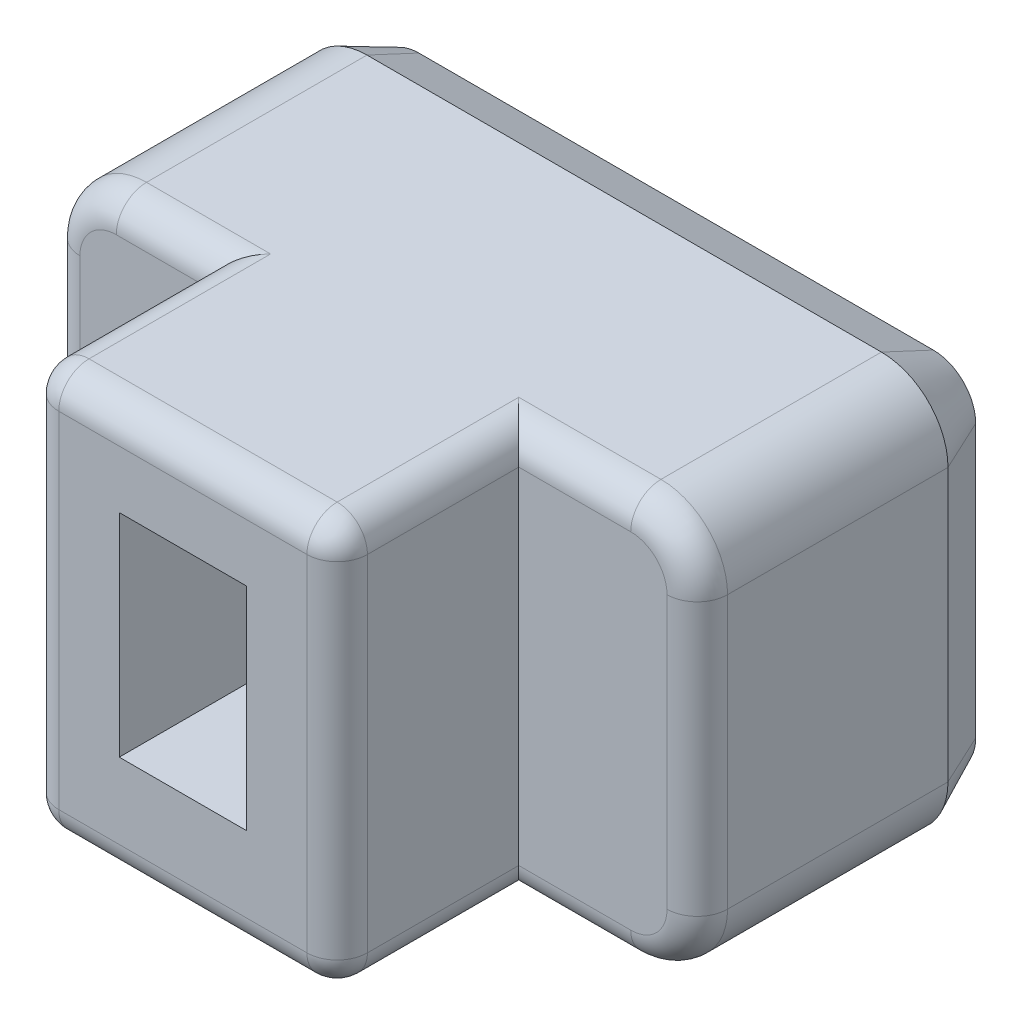
from build123d import *

# Parameters (mm, degrees)
BOSS_EXTRU_1_DEPTH      = 8
ESQUISSE3_W             = 2.1
ESQUISSE3_H             = 3.5
ENL_V_MAT_EXTRU_1_DEPTH = 3
ESQUISSE4_OUTSIDE_W     = 15.69
ESQUISSE4_OUTSIDE_H     = 11.69
ESQUISSE4_OUTSIDE_W_2   = 5.1
ESQUISSE4_OUTSIDE_H_2   = 6.7
ENL_V_MAT_EXTRU_2_DEPTH = 3
CONG_1_R                = 0.5
CHANFREIN1_SIZE         = 0.4
CHANFREIN1_SIZE2        = 0.857802768
ENL_V_MAT_EXTRU_3_DEPTH = 0.2
BOSS_EXTRU_2_DEPTH      = 0.2
BOSS_EXTRU_2_2_DEPTH    = 0.2
BOSS_EXTRU_2_3_DEPTH    = 0.2
BOSS_EXTRU_2_4_DEPTH    = 0.2


with BuildPart() as part:
    # Esquisse2 → Boss.-Extru.1 (new body)
    with BuildSketch(Plane.XY):
        with BuildLine():
            Line((1.1, 0), (9.6, 0))
            ThreePointArc((9.6, 0), (10.377817459, 0.322182541), (10.7, 1.1))
            Line((10.7, 1.1), (10.7, 5.6))
            ThreePointArc((10.7, 5.6), (10.377817459, 6.377817459), (9.6, 6.7))
            Line((9.6, 6.7), (1.1, 6.7))
            ThreePointArc((1.1, 6.7), (0.322182541, 6.377817459), (0, 5.6))
            Line((0, 5.6), (0, 1.1))
            ThreePointArc((0, 1.1), (0.322182541, 0.322182541), (1.1, 0))
        make_face()
    extrude(amount=BOSS_EXTRU_1_DEPTH)

    # Esquisse3 → Enlèv. mat.-Extru.1 (cut)
    with BuildSketch(Plane.XY.offset(8)):
        with Locations((5.2, 3.5)):
            Rectangle(ESQUISSE3_W, ESQUISSE3_H)
    extrude(amount=-ENL_V_MAT_EXTRU_1_DEPTH, mode=Mode.SUBTRACT)

    # Esquisse4 outside → Enlèv. mat.-Extru.2 (cut)
    with BuildSketch(Plane.XY.offset(8)):
        with Locations((5.35, 3.35)):
            Rectangle(ESQUISSE4_OUTSIDE_W, ESQUISSE4_OUTSIDE_H)
        with Locations((5.2, 3.35)):
            Rectangle(ESQUISSE4_OUTSIDE_W_2, ESQUISSE4_OUTSIDE_H_2, mode=Mode.SUBTRACT)
    extrude(amount=-ENL_V_MAT_EXTRU_2_DEPTH, mode=Mode.SUBTRACT)

    # Congé1
    cong_1_edges = [part.edges().sort_by_distance(p)[0] for p in [
        (8.675, 0, 5),
        (10.377817459, 0.322182541, 5),
        (10.7, 3.35, 5),
        (10.377817459, 6.377817459, 5),
        (1.875, 6.7, 5),
        (0.322182541, 6.377817459, 5),
        (1.875, 0, 5),
        (0.322182541, 0.322182541, 5),
        (7.75, 6.7, 6.5),
        (2.65, 6.7, 6.5),
        (7.75, 0, 6.5),
        (2.65, 0, 6.5),
        (2.65, 3.35, 8),
        (5.2, 6.7, 8),
        (7.75, 3.35, 8),
        (5.2, 0, 8),
        (8.675, 6.7, 5),
        (0, 3.35, 5),
    ]]
    fillet(cong_1_edges, radius=CONG_1_R)

    # Chanfrein1
    chanfrein1_edges = [part.edges().sort_by_distance(p)[0] for p in [
        (5.35, 0, 0),
        (10.377817459, 0.322182541, 0),
        (0.322182541, 0.322182541, 0),
        (10.7, 3.35, 0),
        (0, 3.35, 0),
        (10.377817459, 6.377817459, 0),
        (0.322182541, 6.377817459, 0),
        (5.35, 6.7, 0),
    ]]
    chanfrein1_side = [part.faces().sort_by_distance(p)[0] for p in [
        (5.35, 3.35, 0),
    ]]
    chamfer(chanfrein1_edges, length=CHANFREIN1_SIZE, length2=CHANFREIN1_SIZE2, reference=chanfrein1_side[0])

    # Esquisse5 → Enlèv. mat.-Extru.3 (cut)
    # profile 1 of 4: a face of its own
    with BuildSketch(Plane.XY):
        with BuildLine():
            Line((1.20670848, 5.092998901), (0.871123892, 5.092998901))
            Line((0.871123892, 5.092998901), (0.871123892, 1.592998901))
            Line((0.871123892, 1.592998901), (1.634520703, 1.592998901))
            add(Edge.make_bspline(
                [(1.634520703, 1.592998901), (1.689353961, 1.594367518), (1.795246849, 1.597010564), (1.947657519, 1.616349549), (2.088713626, 1.648486034), (2.175088244, 1.683567366), (2.217337355, 1.700726979)],
                knots=[0, 0, 0, 0, 1.102097031, 2.128347664, 3.084503667, 4, 4, 4, 4], degree=3))
            add(Edge.make_bspline(
                [(2.217337355, 1.700726979), (2.256896125, 1.720325727), (2.334514443, 1.75878046), (2.43587247, 1.838600916), (2.524236192, 1.929590111), (2.596121561, 2.03595902), (2.652111876, 2.155507809), (2.691215065, 2.288258291), (2.715784881, 2.433503983), (2.71826512, 2.534804351), (2.719551704, 2.587352311)],
                knots=[0, 0, 0, 0, 0.976045937, 1.915101135, 2.842441065, 3.7778061, 4.74596099, 5.756673503, 6.836309948, 8, 8, 8, 8], degree=3))
            add(Edge.make_bspline(
                [(2.719551704, 2.587352311), (2.718529752, 2.630547217), (2.716546192, 2.71438642), (2.700658457, 2.836048523), (2.675603103, 2.949993543), (2.63887122, 3.055945062), (2.592638071, 3.153883591), (2.536074802, 3.24313122), (2.470857764, 3.324340864), (2.395553699, 3.396786366), (2.31186018, 3.461450443), (2.218513643, 3.516384097), (2.117431288, 3.563907898), (2.007559255, 3.602622144), (1.889407218, 3.632260485), (1.763942002, 3.655261776), (1.630613092, 3.667057182), (1.539470735, 3.669040369), (1.492691651, 3.670058246)],
                knots=[0, 0, 0, 0, 1.113353749, 2.160965244, 3.15799471, 4.11645282, 5.04602989, 5.944145942, 6.834621692, 7.724923037, 8.632205657, 9.555220642, 10.511732549, 11.508227868, 12.553486201, 13.6497118, 14.793707635, 16, 16, 16, 16], degree=3))
            add(Edge.make_bspline(
                [(1.492691651, 3.670058246), (1.445900058, 3.669361357), (1.350371393, 3.667938604), (1.255241901, 3.659078218), (1.20670848, 3.654557803)],
                knots=[0, 0, 0, 0, 0.979634597, 2, 2, 2, 2], degree=3))
            Line((1.20670848, 3.654557803), (1.20670848, 5.092998901))
        make_face()
        with BuildLine():
            add(Edge.make_bspline(
                [(1.20670848, 3.264721664), (1.229671176, 3.268081612), (1.276756003, 3.274971157), (1.3479601, 3.280390103), (1.418758831, 3.284559247), (1.465301481, 3.285290153), (1.488041518, 3.285647262)],
                knots=[0, 0, 0, 0, 0.986049358, 2.021886482, 3.033523553, 4, 4, 4, 4], degree=3))
            add(Edge.make_bspline(
                [(1.488041518, 3.285647262), (1.526033878, 3.285026949), (1.599277371, 3.283831079), (1.704923877, 3.275442513), (1.801915788, 3.26117826), (1.890208061, 3.239996412), (1.970300734, 3.214083964), (2.042403598, 3.181938969), (2.107176038, 3.144981274), (2.16398, 3.102059255), (2.213753248, 3.054596832), (2.254713635, 3.000969926), (2.290242232, 2.943718918), (2.317088589, 2.880777273), (2.338130446, 2.813793991), (2.352715406, 2.742110051), (2.361142672, 2.666090665), (2.362399302, 2.613982705), (2.363041518, 2.587352311)],
                knots=[0, 0, 0, 0, 1.420648392, 2.738794025, 3.960251778, 5.082640406, 6.130503421, 7.103552109, 8.029821208, 8.912811201, 9.75998344, 10.592879125, 11.429575965, 12.273160229, 13.143963859, 14.051504125, 15.004197952, 16, 16, 16, 16], degree=3))
            add(Edge.make_bspline(
                [(2.363041518, 2.587352311), (2.362321145, 2.554733507), (2.360940765, 2.49222923), (2.34573986, 2.402990773), (2.322381391, 2.322667118), (2.288587259, 2.251487343), (2.245313146, 2.18944241), (2.193567559, 2.135680811), (2.134230371, 2.089034617), (2.089609635, 2.065364734), (2.066983059, 2.053362054)],
                knots=[0, 0, 0, 0, 1.207165636, 2.313175352, 3.342544525, 4.297084662, 5.218277657, 6.132034109, 7.052779621, 8, 8, 8, 8], degree=3))
            add(Edge.make_bspline(
                [(2.066983059, 2.053362054), (2.035529134, 2.040463055), (1.969781048, 2.013500298), (1.858571937, 1.991798742), (1.732712702, 1.980100484), (1.643338394, 1.978344496), (1.595769596, 1.977409884)],
                knots=[0, 0, 0, 0, 0.846695568, 1.769846298, 2.813017582, 4, 4, 4, 4], degree=3))
            Line((1.595769596, 1.977409884), (1.20670848, 1.977409884))
            Line((1.20670848, 1.977409884), (1.20670848, 3.264721664))
        make_face(mode=Mode.SUBTRACT)
    # profile 2 of 4: a face of its own
    with BuildSketch(Plane.XY):
        with BuildLine():
            Line((3.339569419, 3.643707493), (3.339569419, 5.092998901))
            Line((3.339569419, 5.092998901), (3.003984831, 5.092998901))
            Line((3.003984831, 5.092998901), (3.003984831, 1.592998901))
            Line((3.003984831, 1.592998901), (3.717780225, 1.592998901))
            add(Edge.make_bspline(
                [(3.717780225, 1.592998901), (3.746982879, 1.592935819), (3.802834183, 1.592815172), (3.883381251, 1.597737699), (3.957195982, 1.601183031), (4.044703681, 1.612039358), (4.145135568, 1.628362438), (4.220721824, 1.65208075), (4.257195637, 1.663525916)],
                knots=[0, 0, 0, 0, 0.96148623, 1.838882832, 2.657282477, 3.393934539, 4.742454682, 6, 6, 6, 6], degree=3))
            add(Edge.make_bspline(
                [(4.257195637, 1.663525916), (4.280609086, 1.672178019), (4.326903922, 1.689285608), (4.392540271, 1.721345141), (4.454432924, 1.757013696), (4.511692206, 1.797599405), (4.565569714, 1.841620067), (4.614649251, 1.890686567), (4.658637934, 1.944584606), (4.699469971, 2.001956268), (4.734605541, 2.064027652), (4.766194985, 2.129270366), (4.791394771, 2.199092325), (4.813285194, 2.271936008), (4.829227361, 2.349035135), (4.841984322, 2.42940088), (4.84872659, 2.513867404), (4.849628953, 2.571324986), (4.850087577, 2.600527688)],
                knots=[0, 0, 0, 0, 1.004278728, 1.985735529, 2.936460815, 3.877064109, 4.807842092, 5.73442736, 6.665205342, 7.605808636, 8.565535541, 9.533119072, 10.520289732, 11.550301557, 12.59263054, 13.686946876, 14.824395376, 16, 16, 16, 16], degree=3))
            add(Edge.make_bspline(
                [(4.850087577, 2.600527688), (4.849569701, 2.634910342), (4.848558825, 2.702024148), (4.838465372, 2.799764421), (4.821149651, 2.89190843), (4.798389226, 2.978664886), (4.768334399, 3.059784167), (4.734190517, 3.135669567), (4.693043686, 3.205346594), (4.647555952, 3.270012568), (4.596055895, 3.328579978), (4.541102893, 3.382907186), (4.48011641, 3.430141905), (4.414672962, 3.471733862), (4.345755669, 3.50971036), (4.271954689, 3.539640604), (4.195474158, 3.567142), (4.142380634, 3.579876517), (4.115366585, 3.586355854)],
                knots=[0, 0, 0, 0, 1.228411642, 2.397818991, 3.505967096, 4.576401872, 5.598614386, 6.594173708, 7.545786843, 8.485911268, 9.41518476, 10.329199726, 11.243354554, 12.165261513, 13.098790089, 14.050403223, 15.008042817, 16, 16, 16, 16], degree=3))
            Line((4.115366585, 3.586355854), (4.115366585, 3.596431142))
            Line((4.115366585, 3.596431142), (5.015167293, 5.092998901))
            Line((5.015167293, 5.092998901), (4.592780225, 5.092998901))
            Line((4.592780225, 5.092998901), (3.744906, 3.643707493))
            Line((3.744906, 3.643707493), (3.339569419, 3.643707493))
        make_face()
        with BuildLine():
            Line((3.339569419, 1.977409884), (3.339569419, 3.259296509))
            Line((3.339569419, 3.259296509), (3.670503874, 3.259296509))
            add(Edge.make_bspline(
                [(3.670503874, 3.259296509), (3.695304806, 3.259133428), (3.742851898, 3.258820777), (3.811635042, 3.256848889), (3.874638922, 3.251764529), (3.949951818, 3.245312963), (4.035695985, 3.23085379), (4.099566685, 3.209195698), (4.130092005, 3.198844782)],
                knots=[0, 0, 0, 0, 0.957884705, 1.836408112, 2.656744154, 3.398369538, 4.756619154, 6, 6, 6, 6], degree=3))
            add(Edge.make_bspline(
                [(4.130092005, 3.198844782), (4.157934618, 3.186806116), (4.212462715, 3.163229106), (4.285696193, 3.113144417), (4.349026944, 3.05297611), (4.402411758, 2.982563114), (4.444290573, 2.900835637), (4.473029143, 2.807752339), (4.491103228, 2.703524253), (4.493236107, 2.630317432), (4.494352413, 2.592002444)],
                knots=[0, 0, 0, 0, 0.958661377, 1.877481189, 2.791628759, 3.714299863, 4.66179935, 5.683601886, 6.787643488, 8, 8, 8, 8], degree=3))
            add(Edge.make_bspline(
                [(4.494352413, 2.592002444), (4.493252095, 2.556261938), (4.491147907, 2.48791375), (4.472923198, 2.391293858), (4.445287627, 2.305165185), (4.406502678, 2.229721317), (4.356606176, 2.165698549), (4.299351757, 2.110302397), (4.233092329, 2.064732747), (4.183717992, 2.043278074), (4.158767825, 2.032436456)],
                knots=[0, 0, 0, 0, 1.228800359, 2.349890542, 3.370317647, 4.332513309, 5.251741842, 6.15080521, 7.065552617, 8, 8, 8, 8], degree=3))
            add(Edge.make_bspline(
                [(4.158767825, 2.032436456), (4.131820833, 2.023499284), (4.073957624, 2.004308515), (3.995358463, 1.991386976), (3.92399037, 1.984871624), (3.8622725, 1.979816467), (3.793486428, 1.977877641), (3.745422803, 1.977571267), (3.720105291, 1.977409884)],
                knots=[0, 0, 0, 0, 1.148741759, 2.466690436, 3.213321058, 4.052887216, 4.974358485, 6, 6, 6, 6], degree=3))
            Line((3.720105291, 1.977409884), (3.339569419, 1.977409884))
        make_face(mode=Mode.SUBTRACT)
    # profile 3 of 4: a face of its own
    with BuildSketch(Plane.XY):
        with BuildLine():
            add(Edge.make_bspline(
                [(7.71844453, 3.345323967), (7.717490823, 3.410204476), (7.715617955, 3.537615321), (7.698300865, 3.724589286), (7.669558866, 3.90344507), (7.630568495, 4.073779802), (7.580167736, 4.234037989), (7.520625348, 4.383832581), (7.451011567, 4.521908825), (7.371748918, 4.648620785), (7.282545439, 4.762283337), (7.185578837, 4.864405018), (7.078408921, 4.95147494), (6.963535828, 5.025627742), (6.840555598, 5.084922143), (6.709957694, 5.128180687), (6.571846524, 5.153103959), (6.477474066, 5.156418649), (6.429582705, 5.158100761)],
                knots=[0, 0, 0, 0, 1.254401412, 2.463364559, 3.627141903, 4.75533473, 5.83922306, 6.872651372, 7.869084623, 8.825439613, 9.757825438, 10.658779487, 11.542787756, 12.421358886, 13.297241529, 14.175599587, 15.074168247, 16, 16, 16, 16], degree=3))
            add(Edge.make_bspline(
                [(6.429582705, 5.158100761), (6.380139139, 5.156448782), (6.283192758, 5.153209667), (6.141537726, 5.128126273), (6.008179731, 5.085294289), (5.883344048, 5.025541428), (5.766945237, 4.952015382), (5.659775215, 4.864019715), (5.561704334, 4.763090778), (5.474522259, 4.648005694), (5.394739066, 4.522193813), (5.326280438, 4.383725792), (5.267139118, 4.23416755), (5.218785937, 4.073586542), (5.180247458, 3.90344204), (5.152322236, 3.724555778), (5.136004659, 3.537578413), (5.133994475, 3.410199769), (5.132970659, 3.345323967)],
                knots=[0, 0, 0, 0, 0.95135505, 1.865367647, 2.758596585, 3.639420318, 4.522333025, 5.402272009, 6.302532509, 7.224531664, 8.17648434, 9.166096968, 10.192927605, 11.268888898, 12.390775886, 13.548416718, 14.751372875, 16, 16, 16, 16], degree=3))
            add(Edge.make_bspline(
                [(5.132970659, 3.345323967), (5.133909926, 3.279924761), (5.135750982, 3.151735858), (5.153201585, 2.963758231), (5.181562496, 2.783975058), (5.221957953, 2.613154279), (5.271590455, 2.451965447), (5.332525486, 2.302332204), (5.40211655, 2.163948858), (5.480816103, 2.037035708), (5.569885489, 1.923447935), (5.666578795, 1.821540487), (5.774026866, 1.734641948), (5.88857793, 1.659320523), (6.012320582, 1.600141415), (6.143708493, 1.55815348), (6.282379938, 1.532716971), (6.377289501, 1.529525281), (6.425707594, 1.527897041)],
                knots=[0, 0, 0, 0, 1.2604387, 2.470584333, 3.635642921, 4.76629325, 5.851547647, 6.883611372, 7.876931566, 8.834516682, 9.756999016, 10.655138303, 11.536384754, 12.414911192, 13.292547926, 14.171356622, 15.067117974, 16, 16, 16, 16], degree=3))
            add(Edge.make_bspline(
                [(6.425707594, 1.527897041), (6.474898321, 1.529530042), (6.571342357, 1.532731728), (6.712082462, 1.55806652), (6.845078706, 1.599968235), (6.969763269, 1.659351787), (7.085036042, 1.734402747), (7.192578769, 1.821561914), (7.289242198, 1.923467324), (7.378431123, 2.036823797), (7.456190042, 2.164031677), (7.525243653, 2.302191567), (7.584408512, 2.45206405), (7.63252958, 2.613207532), (7.671496284, 2.784025202), (7.69777052, 2.963900011), (7.715784212, 3.151719212), (7.717545804, 3.279919138), (7.71844453, 3.345323967)],
                knots=[0, 0, 0, 0, 0.945875137, 1.854496205, 2.740991389, 3.62133533, 4.502254271, 5.381713945, 6.278032205, 7.198644155, 8.151660626, 9.140734204, 10.167005517, 11.247136334, 12.373259138, 13.534424914, 14.742116909, 16, 16, 16, 16], degree=3))
        make_face()
        with BuildLine():
            add(Edge.make_bspline(
                [(7.36425941, 3.345323967), (7.363354318, 3.28820498), (7.361598928, 3.177425057), (7.348433043, 3.01638856), (7.326324974, 2.865602316), (7.294636917, 2.725517513), (7.255145807, 2.596265005), (7.208639661, 2.478131695), (7.156071809, 2.370489112), (7.096713344, 2.273632496), (7.029160994, 2.189249979), (6.958267959, 2.113595029), (6.879912968, 2.050662233), (6.796874023, 1.998149659), (6.708762004, 1.958131515), (6.617491987, 1.927858599), (6.522438515, 1.910864821), (6.458062135, 1.908214752), (6.425707594, 1.906882869)],
                knots=[0, 0, 0, 0, 1.431659839, 2.776645253, 4.046892239, 5.248691002, 6.373248433, 7.431467862, 8.427717902, 9.372927974, 10.27202652, 11.133077176, 11.96643372, 12.783965196, 13.589482426, 14.386100375, 15.188879826, 16, 16, 16, 16], degree=3))
            add(Edge.make_bspline(
                [(6.425707594, 1.906882869), (6.393352979, 1.908214682), (6.32897645, 1.910864612), (6.233924081, 1.927859421), (6.142649901, 1.958128445), (6.054553658, 1.99816134), (5.971454451, 2.050617568), (5.89319208, 2.113880581), (5.821396868, 2.188722678), (5.754775476, 2.273920937), (5.695491357, 2.370663517), (5.641630598, 2.477745284), (5.596568914, 2.596488274), (5.556681609, 2.72547817), (5.525118461, 2.865613813), (5.502973947, 3.016385224), (5.489818517, 3.177425975), (5.488061639, 3.288205292), (5.487155779, 3.345323967)],
                knots=[0, 0, 0, 0, 0.81106871, 1.613797227, 2.410364633, 3.215830754, 4.03331036, 4.86661403, 5.732102977, 6.627148042, 7.572298143, 8.57136398, 9.627155934, 10.751642014, 11.953364526, 13.223530918, 14.568430996, 16, 16, 16, 16], degree=3))
            add(Edge.make_bspline(
                [(5.487155779, 3.345323967), (5.48810114, 3.402437635), (5.489938892, 3.513464713), (5.50258263, 3.674613838), (5.526108626, 3.824975597), (5.557581256, 3.964606764), (5.597132843, 4.093571347), (5.643223298, 4.211758064), (5.697042295, 4.318872581), (5.757247215, 4.41490553), (5.823397966, 4.500425204), (5.89584375, 4.574357032), (5.973495221, 4.637894177), (6.057164378, 4.689142394), (6.144985026, 4.729894191), (6.236981307, 4.758468335), (6.332273497, 4.77625025), (6.396954406, 4.778154389), (6.429582705, 4.779114933)],
                knots=[0, 0, 0, 0, 1.43184294, 2.783455283, 4.048438288, 5.244075095, 6.36877635, 7.42713112, 8.420599559, 9.369363064, 10.264579399, 11.125594041, 11.959057166, 12.773274533, 13.578894784, 14.379815369, 15.182697491, 16, 16, 16, 16], degree=3))
            add(Edge.make_bspline(
                [(6.429582705, 4.779114933), (6.461950884, 4.778146752), (6.526115323, 4.776227496), (6.6204308, 4.758602085), (6.711299616, 4.729711271), (6.798144113, 4.689143205), (6.881065287, 4.637894479), (6.957951652, 4.574110175), (7.030333788, 4.500432503), (7.096541848, 4.415099793), (7.155931452, 4.318826963), (7.208825397, 4.211567097), (7.255125763, 4.093598017), (7.294529869, 3.964589912), (7.326337072, 3.825055477), (7.34853709, 3.67452883), (7.361558319, 3.513477368), (7.36334191, 3.402441933), (7.36425941, 3.345323967)],
                knots=[0, 0, 0, 0, 0.813321926, 1.612273121, 2.403261148, 3.205454394, 4.016646045, 4.847626393, 5.711280782, 6.609241721, 7.557470929, 8.551079935, 9.612679468, 10.740828895, 11.940131352, 13.208011044, 14.563767236, 16, 16, 16, 16], degree=3))
        make_face(mode=Mode.SUBTRACT)
    # profile 4 of 4: a face of its own
    with BuildSketch(Plane.XY):
        with BuildLine():
            add(Edge.make_bspline(
                [(9.401017603, 1.906882869), (9.363499186, 1.90818258), (9.289367236, 1.910750655), (9.179784589, 1.927987062), (9.074406065, 1.957680591), (8.972941262, 1.998155453), (8.876272181, 2.049711686), (8.787273041, 2.115127472), (8.703129014, 2.189927999), (8.6266481, 2.277014469), (8.557354227, 2.375648594), (8.495491166, 2.484876528), (8.441894475, 2.605401829), (8.396307884, 2.736821056), (8.358904164, 2.879448886), (8.332974512, 3.033754076), (8.317527869, 3.199044062), (8.315487307, 3.312996837), (8.314436558, 3.37167472)],
                knots=[0, 0, 0, 0, 0.879992269, 1.7387605, 2.594444558, 3.442888612, 4.296961918, 5.156371292, 6.027472405, 6.933290606, 7.86807611, 8.85043868, 9.873020297, 10.957722873, 12.11002158, 13.327402364, 14.62379506, 16, 16, 16, 16], degree=3))
            add(Edge.make_bspline(
                [(8.314436558, 3.37167472), (8.315218843, 3.429832766), (8.316733983, 3.542474004), (8.331469627, 3.705407432), (8.35616246, 3.856406629), (8.389869406, 3.995749624), (8.433439182, 4.123176742), (8.484558712, 4.239617688), (8.543800679, 4.344865165), (8.612841547, 4.437547604), (8.688288843, 4.519864001), (8.771631718, 4.590997053), (8.862922426, 4.650179716), (8.961471347, 4.69771972), (9.066482804, 4.733763946), (9.176983442, 4.76031743), (9.293359199, 4.775961769), (9.372811, 4.778048452), (9.413417957, 4.779114933)],
                knots=[0, 0, 0, 0, 1.376668534, 2.666348994, 3.868955176, 4.996373325, 6.056321508, 7.053061798, 8.00363822, 8.908879053, 9.783196614, 10.642321006, 11.495656305, 12.35188012, 13.226197681, 14.119268927, 15.038778669, 16, 16, 16, 16], degree=3))
            add(Edge.make_bspline(
                [(9.413417957, 4.779114933), (9.436685656, 4.778644332), (9.484867225, 4.777669834), (9.558292286, 4.770182928), (9.634422492, 4.759659113), (9.710868671, 4.744021918), (9.786810014, 4.725384649), (9.85992275, 4.704658998), (9.92889931, 4.683436183), (9.971319827, 4.66479261), (9.991584476, 4.655886412)],
                knots=[0, 0, 0, 0, 0.938891291, 1.944208406, 2.976362877, 4.039644555, 5.091619871, 6.131382141, 7.107344988, 8, 8, 8, 8], degree=3))
            Line((9.991584476, 4.655886412), (9.991584476, 5.032547174))
            add(Edge.make_bspline(
                [(9.991584476, 5.032547174), (9.970816832, 5.042481872), (9.928211789, 5.062863012), (9.859667897, 5.086888391), (9.786867029, 5.10895653), (9.682671068, 5.132238066), (9.547076979, 5.15419478), (9.436512363, 5.15679308), (9.380867027, 5.158100761)],
                knots=[0, 0, 0, 0, 0.65879011, 1.351514929, 2.077116164, 2.836224988, 4.407724579, 6, 6, 6, 6], degree=3))
            add(Edge.make_bspline(
                [(9.380867027, 5.158100761), (9.324987198, 5.156628633), (9.216114259, 5.153760427), (9.057839708, 5.131006778), (8.909454511, 5.093388589), (8.771411734, 5.039183231), (8.643186281, 4.972071609), (8.525560507, 4.890532912), (8.419249455, 4.795470688), (8.322996198, 4.687766873), (8.238724426, 4.566536774), (8.163623012, 4.433879772), (8.102084701, 4.287299743), (8.050372026, 4.129182281), (8.009202649, 3.959507315), (7.981301328, 3.778263776), (7.962740199, 3.586485504), (7.961093965, 3.454648191), (7.960251438, 3.387175163)],
                knots=[0, 0, 0, 0, 1.042402955, 2.030955957, 2.976872811, 3.892693394, 4.79191998, 5.671840379, 6.556199892, 7.447365694, 8.360848699, 9.30622489, 10.286740406, 11.321861055, 12.408087922, 13.540642029, 14.741325001, 16, 16, 16, 16], degree=3))
            add(Edge.make_bspline(
                [(7.960251438, 3.387175163), (7.961486458, 3.320487695), (7.963908384, 3.189710631), (7.981631912, 2.997442746), (8.012838575, 2.813658607), (8.055019781, 2.638393656), (8.109156307, 2.473276979), (8.173988439, 2.31926326), (8.250293058, 2.177310496), (8.336987814, 2.047574907), (8.434011591, 1.930522095), (8.541833875, 1.82748378), (8.659285388, 1.737978092), (8.785957559, 1.662353558), (8.921730606, 1.602267564), (9.065808285, 1.558675263), (9.218455729, 1.532556005), (9.322895701, 1.529471709), (9.376216895, 1.527897041)],
                knots=[0, 0, 0, 0, 1.222049748, 2.396493403, 3.534403425, 4.635595668, 5.697072746, 6.715343596, 7.693969664, 8.645951101, 9.57036278, 10.474462782, 11.373067138, 12.271072658, 13.171906666, 14.087009169, 15.023334156, 16, 16, 16, 16], degree=3))
            add(Edge.make_bspline(
                [(9.376216895, 1.527897041), (9.40489793, 1.528442114), (9.46206628, 1.529528577), (9.547049742, 1.535224163), (9.629390208, 1.547496167), (9.708229495, 1.561479632), (9.782091473, 1.580508862), (9.850432382, 1.601443109), (9.911221925, 1.625913241), (9.948039326, 1.644684233), (9.965233724, 1.653450628)],
                knots=[0, 0, 0, 0, 1.132578206, 2.257506571, 3.35954441, 4.417807573, 5.417220349, 6.368856758, 7.238226401, 8, 8, 8, 8], degree=3))
            Line((9.965233724, 1.653450628), (9.965233724, 2.03011139))
            add(Edge.make_bspline(
                [(9.965233724, 2.03011139), (9.922312104, 2.013453379), (9.834015078, 1.979185037), (9.694921987, 1.939289388), (9.549336302, 1.911645899), (9.450224476, 1.908463073), (9.401017603, 1.906882869)],
                knots=[0, 0, 0, 0, 0.950326369, 1.954981939, 2.984692879, 4, 4, 4, 4], degree=3))
        make_face()
    extrude(amount=ENL_V_MAT_EXTRU_3_DEPTH, mode=Mode.SUBTRACT)


with BuildPart() as body_2:
    # Esquisse5_4 → Boss.-Extru.2 (new body)
    with BuildSketch(Plane.XY):
        with BuildLine():
            Line((1.20670848, 5.092998901), (0.871123892, 5.092998901))
            Line((0.871123892, 5.092998901), (0.871123892, 1.592998901))
            Line((0.871123892, 1.592998901), (1.634520703, 1.592998901))
            add(Edge.make_bspline(
                [(1.634520703, 1.592998901), (1.689353961, 1.594367518), (1.795246849, 1.597010564), (1.947657519, 1.616349549), (2.088713626, 1.648486034), (2.175088244, 1.683567366), (2.217337355, 1.700726979)],
                knots=[0, 0, 0, 0, 1.102097031, 2.128347664, 3.084503667, 4, 4, 4, 4], degree=3))
            add(Edge.make_bspline(
                [(2.217337355, 1.700726979), (2.256896125, 1.720325727), (2.334514443, 1.75878046), (2.43587247, 1.838600916), (2.524236192, 1.929590111), (2.596121561, 2.03595902), (2.652111876, 2.155507809), (2.691215065, 2.288258291), (2.715784881, 2.433503983), (2.71826512, 2.534804351), (2.719551704, 2.587352311)],
                knots=[0, 0, 0, 0, 0.976045937, 1.915101135, 2.842441065, 3.7778061, 4.74596099, 5.756673503, 6.836309948, 8, 8, 8, 8], degree=3))
            add(Edge.make_bspline(
                [(2.719551704, 2.587352311), (2.718529752, 2.630547217), (2.716546192, 2.71438642), (2.700658457, 2.836048523), (2.675603103, 2.949993543), (2.63887122, 3.055945062), (2.592638071, 3.153883591), (2.536074802, 3.24313122), (2.470857764, 3.324340864), (2.395553699, 3.396786366), (2.31186018, 3.461450443), (2.218513643, 3.516384097), (2.117431288, 3.563907898), (2.007559255, 3.602622144), (1.889407218, 3.632260485), (1.763942002, 3.655261776), (1.630613092, 3.667057182), (1.539470735, 3.669040369), (1.492691651, 3.670058246)],
                knots=[0, 0, 0, 0, 1.113353749, 2.160965244, 3.15799471, 4.11645282, 5.04602989, 5.944145942, 6.834621692, 7.724923037, 8.632205657, 9.555220642, 10.511732549, 11.508227868, 12.553486201, 13.6497118, 14.793707635, 16, 16, 16, 16], degree=3))
            add(Edge.make_bspline(
                [(1.492691651, 3.670058246), (1.445900058, 3.669361357), (1.350371393, 3.667938604), (1.255241901, 3.659078218), (1.20670848, 3.654557803)],
                knots=[0, 0, 0, 0, 0.979634597, 2, 2, 2, 2], degree=3))
            Line((1.20670848, 3.654557803), (1.20670848, 5.092998901))
        make_face()
        with BuildLine():
            add(Edge.make_bspline(
                [(1.20670848, 3.264721664), (1.229671176, 3.268081612), (1.276756003, 3.274971157), (1.3479601, 3.280390103), (1.418758831, 3.284559247), (1.465301481, 3.285290153), (1.488041518, 3.285647262)],
                knots=[0, 0, 0, 0, 0.986049358, 2.021886482, 3.033523553, 4, 4, 4, 4], degree=3))
            add(Edge.make_bspline(
                [(1.488041518, 3.285647262), (1.526033878, 3.285026949), (1.599277371, 3.283831079), (1.704923877, 3.275442513), (1.801915788, 3.26117826), (1.890208061, 3.239996412), (1.970300734, 3.214083964), (2.042403598, 3.181938969), (2.107176038, 3.144981274), (2.16398, 3.102059255), (2.213753248, 3.054596832), (2.254713635, 3.000969926), (2.290242232, 2.943718918), (2.317088589, 2.880777273), (2.338130446, 2.813793991), (2.352715406, 2.742110051), (2.361142672, 2.666090665), (2.362399302, 2.613982705), (2.363041518, 2.587352311)],
                knots=[0, 0, 0, 0, 1.420648392, 2.738794025, 3.960251778, 5.082640406, 6.130503421, 7.103552109, 8.029821208, 8.912811201, 9.75998344, 10.592879125, 11.429575965, 12.273160229, 13.143963859, 14.051504125, 15.004197952, 16, 16, 16, 16], degree=3))
            add(Edge.make_bspline(
                [(2.363041518, 2.587352311), (2.362321145, 2.554733507), (2.360940765, 2.49222923), (2.34573986, 2.402990773), (2.322381391, 2.322667118), (2.288587259, 2.251487343), (2.245313146, 2.18944241), (2.193567559, 2.135680811), (2.134230371, 2.089034617), (2.089609635, 2.065364734), (2.066983059, 2.053362054)],
                knots=[0, 0, 0, 0, 1.207165636, 2.313175352, 3.342544525, 4.297084662, 5.218277657, 6.132034109, 7.052779621, 8, 8, 8, 8], degree=3))
            add(Edge.make_bspline(
                [(2.066983059, 2.053362054), (2.035529134, 2.040463055), (1.969781048, 2.013500298), (1.858571937, 1.991798742), (1.732712702, 1.980100484), (1.643338394, 1.978344496), (1.595769596, 1.977409884)],
                knots=[0, 0, 0, 0, 0.846695568, 1.769846298, 2.813017582, 4, 4, 4, 4], degree=3))
            Line((1.595769596, 1.977409884), (1.20670848, 1.977409884))
            Line((1.20670848, 1.977409884), (1.20670848, 3.264721664))
        make_face(mode=Mode.SUBTRACT)
    extrude(amount=-BOSS_EXTRU_2_DEPTH)


with BuildPart() as body_3:
    # Esquisse5_4 → Boss.-Extru.2 2 (new body)
    with BuildSketch(Plane.XY):
        with BuildLine():
            Line((3.339569419, 3.643707493), (3.339569419, 5.092998901))
            Line((3.339569419, 5.092998901), (3.003984831, 5.092998901))
            Line((3.003984831, 5.092998901), (3.003984831, 1.592998901))
            Line((3.003984831, 1.592998901), (3.717780225, 1.592998901))
            add(Edge.make_bspline(
                [(3.717780225, 1.592998901), (3.746982879, 1.592935819), (3.802834183, 1.592815172), (3.883381251, 1.597737699), (3.957195982, 1.601183031), (4.044703681, 1.612039358), (4.145135568, 1.628362438), (4.220721824, 1.65208075), (4.257195637, 1.663525916)],
                knots=[0, 0, 0, 0, 0.96148623, 1.838882832, 2.657282477, 3.393934539, 4.742454682, 6, 6, 6, 6], degree=3))
            add(Edge.make_bspline(
                [(4.257195637, 1.663525916), (4.280609086, 1.672178019), (4.326903922, 1.689285608), (4.392540271, 1.721345141), (4.454432924, 1.757013696), (4.511692206, 1.797599405), (4.565569714, 1.841620067), (4.614649251, 1.890686567), (4.658637934, 1.944584606), (4.699469971, 2.001956268), (4.734605541, 2.064027652), (4.766194985, 2.129270366), (4.791394771, 2.199092325), (4.813285194, 2.271936008), (4.829227361, 2.349035135), (4.841984322, 2.42940088), (4.84872659, 2.513867404), (4.849628953, 2.571324986), (4.850087577, 2.600527688)],
                knots=[0, 0, 0, 0, 1.004278728, 1.985735529, 2.936460815, 3.877064109, 4.807842092, 5.73442736, 6.665205342, 7.605808636, 8.565535541, 9.533119072, 10.520289732, 11.550301557, 12.59263054, 13.686946876, 14.824395376, 16, 16, 16, 16], degree=3))
            add(Edge.make_bspline(
                [(4.850087577, 2.600527688), (4.849569701, 2.634910342), (4.848558825, 2.702024148), (4.838465372, 2.799764421), (4.821149651, 2.89190843), (4.798389226, 2.978664886), (4.768334399, 3.059784167), (4.734190517, 3.135669567), (4.693043686, 3.205346594), (4.647555952, 3.270012568), (4.596055895, 3.328579978), (4.541102893, 3.382907186), (4.48011641, 3.430141905), (4.414672962, 3.471733862), (4.345755669, 3.50971036), (4.271954689, 3.539640604), (4.195474158, 3.567142), (4.142380634, 3.579876517), (4.115366585, 3.586355854)],
                knots=[0, 0, 0, 0, 1.228411642, 2.397818991, 3.505967096, 4.576401872, 5.598614386, 6.594173708, 7.545786843, 8.485911268, 9.41518476, 10.329199726, 11.243354554, 12.165261513, 13.098790089, 14.050403223, 15.008042817, 16, 16, 16, 16], degree=3))
            Line((4.115366585, 3.586355854), (4.115366585, 3.596431142))
            Line((4.115366585, 3.596431142), (5.015167293, 5.092998901))
            Line((5.015167293, 5.092998901), (4.592780225, 5.092998901))
            Line((4.592780225, 5.092998901), (3.744906, 3.643707493))
            Line((3.744906, 3.643707493), (3.339569419, 3.643707493))
        make_face()
        with BuildLine():
            Line((3.339569419, 1.977409884), (3.339569419, 3.259296509))
            Line((3.339569419, 3.259296509), (3.670503874, 3.259296509))
            add(Edge.make_bspline(
                [(3.670503874, 3.259296509), (3.695304806, 3.259133428), (3.742851898, 3.258820777), (3.811635042, 3.256848889), (3.874638922, 3.251764529), (3.949951818, 3.245312963), (4.035695985, 3.23085379), (4.099566685, 3.209195698), (4.130092005, 3.198844782)],
                knots=[0, 0, 0, 0, 0.957884705, 1.836408112, 2.656744154, 3.398369538, 4.756619154, 6, 6, 6, 6], degree=3))
            add(Edge.make_bspline(
                [(4.130092005, 3.198844782), (4.157934618, 3.186806116), (4.212462715, 3.163229106), (4.285696193, 3.113144417), (4.349026944, 3.05297611), (4.402411758, 2.982563114), (4.444290573, 2.900835637), (4.473029143, 2.807752339), (4.491103228, 2.703524253), (4.493236107, 2.630317432), (4.494352413, 2.592002444)],
                knots=[0, 0, 0, 0, 0.958661377, 1.877481189, 2.791628759, 3.714299863, 4.66179935, 5.683601886, 6.787643488, 8, 8, 8, 8], degree=3))
            add(Edge.make_bspline(
                [(4.494352413, 2.592002444), (4.493252095, 2.556261938), (4.491147907, 2.48791375), (4.472923198, 2.391293858), (4.445287627, 2.305165185), (4.406502678, 2.229721317), (4.356606176, 2.165698549), (4.299351757, 2.110302397), (4.233092329, 2.064732747), (4.183717992, 2.043278074), (4.158767825, 2.032436456)],
                knots=[0, 0, 0, 0, 1.228800359, 2.349890542, 3.370317647, 4.332513309, 5.251741842, 6.15080521, 7.065552617, 8, 8, 8, 8], degree=3))
            add(Edge.make_bspline(
                [(4.158767825, 2.032436456), (4.131820833, 2.023499284), (4.073957624, 2.004308515), (3.995358463, 1.991386976), (3.92399037, 1.984871624), (3.8622725, 1.979816467), (3.793486428, 1.977877641), (3.745422803, 1.977571267), (3.720105291, 1.977409884)],
                knots=[0, 0, 0, 0, 1.148741759, 2.466690436, 3.213321058, 4.052887216, 4.974358485, 6, 6, 6, 6], degree=3))
            Line((3.720105291, 1.977409884), (3.339569419, 1.977409884))
        make_face(mode=Mode.SUBTRACT)
    extrude(amount=-BOSS_EXTRU_2_2_DEPTH)


with BuildPart() as body_4:
    # Esquisse5_4 → Boss.-Extru.2 3 (new body)
    with BuildSketch(Plane.XY):
        with BuildLine():
            add(Edge.make_bspline(
                [(7.71844453, 3.345323967), (7.717490823, 3.410204476), (7.715617955, 3.537615321), (7.698300865, 3.724589286), (7.669558866, 3.90344507), (7.630568495, 4.073779802), (7.580167736, 4.234037989), (7.520625348, 4.383832581), (7.451011567, 4.521908825), (7.371748918, 4.648620785), (7.282545439, 4.762283337), (7.185578837, 4.864405018), (7.078408921, 4.95147494), (6.963535828, 5.025627742), (6.840555598, 5.084922143), (6.709957694, 5.128180687), (6.571846524, 5.153103959), (6.477474066, 5.156418649), (6.429582705, 5.158100761)],
                knots=[0, 0, 0, 0, 1.254401412, 2.463364559, 3.627141903, 4.75533473, 5.83922306, 6.872651372, 7.869084623, 8.825439613, 9.757825438, 10.658779487, 11.542787756, 12.421358886, 13.297241529, 14.175599587, 15.074168247, 16, 16, 16, 16], degree=3))
            add(Edge.make_bspline(
                [(6.429582705, 5.158100761), (6.380139139, 5.156448782), (6.283192758, 5.153209667), (6.141537726, 5.128126273), (6.008179731, 5.085294289), (5.883344048, 5.025541428), (5.766945237, 4.952015382), (5.659775215, 4.864019715), (5.561704334, 4.763090778), (5.474522259, 4.648005694), (5.394739066, 4.522193813), (5.326280438, 4.383725792), (5.267139118, 4.23416755), (5.218785937, 4.073586542), (5.180247458, 3.90344204), (5.152322236, 3.724555778), (5.136004659, 3.537578413), (5.133994475, 3.410199769), (5.132970659, 3.345323967)],
                knots=[0, 0, 0, 0, 0.95135505, 1.865367647, 2.758596585, 3.639420318, 4.522333025, 5.402272009, 6.302532509, 7.224531664, 8.17648434, 9.166096968, 10.192927605, 11.268888898, 12.390775886, 13.548416718, 14.751372875, 16, 16, 16, 16], degree=3))
            add(Edge.make_bspline(
                [(5.132970659, 3.345323967), (5.133909926, 3.279924761), (5.135750982, 3.151735858), (5.153201585, 2.963758231), (5.181562496, 2.783975058), (5.221957953, 2.613154279), (5.271590455, 2.451965447), (5.332525486, 2.302332204), (5.40211655, 2.163948858), (5.480816103, 2.037035708), (5.569885489, 1.923447935), (5.666578795, 1.821540487), (5.774026866, 1.734641948), (5.88857793, 1.659320523), (6.012320582, 1.600141415), (6.143708493, 1.55815348), (6.282379938, 1.532716971), (6.377289501, 1.529525281), (6.425707594, 1.527897041)],
                knots=[0, 0, 0, 0, 1.2604387, 2.470584333, 3.635642921, 4.76629325, 5.851547647, 6.883611372, 7.876931566, 8.834516682, 9.756999016, 10.655138303, 11.536384754, 12.414911192, 13.292547926, 14.171356622, 15.067117974, 16, 16, 16, 16], degree=3))
            add(Edge.make_bspline(
                [(6.425707594, 1.527897041), (6.474898321, 1.529530042), (6.571342357, 1.532731728), (6.712082462, 1.55806652), (6.845078706, 1.599968235), (6.969763269, 1.659351787), (7.085036042, 1.734402747), (7.192578769, 1.821561914), (7.289242198, 1.923467324), (7.378431123, 2.036823797), (7.456190042, 2.164031677), (7.525243653, 2.302191567), (7.584408512, 2.45206405), (7.63252958, 2.613207532), (7.671496284, 2.784025202), (7.69777052, 2.963900011), (7.715784212, 3.151719212), (7.717545804, 3.279919138), (7.71844453, 3.345323967)],
                knots=[0, 0, 0, 0, 0.945875137, 1.854496205, 2.740991389, 3.62133533, 4.502254271, 5.381713945, 6.278032205, 7.198644155, 8.151660626, 9.140734204, 10.167005517, 11.247136334, 12.373259138, 13.534424914, 14.742116909, 16, 16, 16, 16], degree=3))
        make_face()
        with BuildLine():
            add(Edge.make_bspline(
                [(7.36425941, 3.345323967), (7.363354318, 3.28820498), (7.361598928, 3.177425057), (7.348433043, 3.01638856), (7.326324974, 2.865602316), (7.294636917, 2.725517513), (7.255145807, 2.596265005), (7.208639661, 2.478131695), (7.156071809, 2.370489112), (7.096713344, 2.273632496), (7.029160994, 2.189249979), (6.958267959, 2.113595029), (6.879912968, 2.050662233), (6.796874023, 1.998149659), (6.708762004, 1.958131515), (6.617491987, 1.927858599), (6.522438515, 1.910864821), (6.458062135, 1.908214752), (6.425707594, 1.906882869)],
                knots=[0, 0, 0, 0, 1.431659839, 2.776645253, 4.046892239, 5.248691002, 6.373248433, 7.431467862, 8.427717902, 9.372927974, 10.27202652, 11.133077176, 11.96643372, 12.783965196, 13.589482426, 14.386100375, 15.188879826, 16, 16, 16, 16], degree=3))
            add(Edge.make_bspline(
                [(6.425707594, 1.906882869), (6.393352979, 1.908214682), (6.32897645, 1.910864612), (6.233924081, 1.927859421), (6.142649901, 1.958128445), (6.054553658, 1.99816134), (5.971454451, 2.050617568), (5.89319208, 2.113880581), (5.821396868, 2.188722678), (5.754775476, 2.273920937), (5.695491357, 2.370663517), (5.641630598, 2.477745284), (5.596568914, 2.596488274), (5.556681609, 2.72547817), (5.525118461, 2.865613813), (5.502973947, 3.016385224), (5.489818517, 3.177425975), (5.488061639, 3.288205292), (5.487155779, 3.345323967)],
                knots=[0, 0, 0, 0, 0.81106871, 1.613797227, 2.410364633, 3.215830754, 4.03331036, 4.86661403, 5.732102977, 6.627148042, 7.572298143, 8.57136398, 9.627155934, 10.751642014, 11.953364526, 13.223530918, 14.568430996, 16, 16, 16, 16], degree=3))
            add(Edge.make_bspline(
                [(5.487155779, 3.345323967), (5.48810114, 3.402437635), (5.489938892, 3.513464713), (5.50258263, 3.674613838), (5.526108626, 3.824975597), (5.557581256, 3.964606764), (5.597132843, 4.093571347), (5.643223298, 4.211758064), (5.697042295, 4.318872581), (5.757247215, 4.41490553), (5.823397966, 4.500425204), (5.89584375, 4.574357032), (5.973495221, 4.637894177), (6.057164378, 4.689142394), (6.144985026, 4.729894191), (6.236981307, 4.758468335), (6.332273497, 4.77625025), (6.396954406, 4.778154389), (6.429582705, 4.779114933)],
                knots=[0, 0, 0, 0, 1.43184294, 2.783455283, 4.048438288, 5.244075095, 6.36877635, 7.42713112, 8.420599559, 9.369363064, 10.264579399, 11.125594041, 11.959057166, 12.773274533, 13.578894784, 14.379815369, 15.182697491, 16, 16, 16, 16], degree=3))
            add(Edge.make_bspline(
                [(6.429582705, 4.779114933), (6.461950884, 4.778146752), (6.526115323, 4.776227496), (6.6204308, 4.758602085), (6.711299616, 4.729711271), (6.798144113, 4.689143205), (6.881065287, 4.637894479), (6.957951652, 4.574110175), (7.030333788, 4.500432503), (7.096541848, 4.415099793), (7.155931452, 4.318826963), (7.208825397, 4.211567097), (7.255125763, 4.093598017), (7.294529869, 3.964589912), (7.326337072, 3.825055477), (7.34853709, 3.67452883), (7.361558319, 3.513477368), (7.36334191, 3.402441933), (7.36425941, 3.345323967)],
                knots=[0, 0, 0, 0, 0.813321926, 1.612273121, 2.403261148, 3.205454394, 4.016646045, 4.847626393, 5.711280782, 6.609241721, 7.557470929, 8.551079935, 9.612679468, 10.740828895, 11.940131352, 13.208011044, 14.563767236, 16, 16, 16, 16], degree=3))
        make_face(mode=Mode.SUBTRACT)
    extrude(amount=-BOSS_EXTRU_2_3_DEPTH)


with BuildPart() as body_5:
    # Esquisse5_4 → Boss.-Extru.2 4 (new body)
    with BuildSketch(Plane.XY):
        with BuildLine():
            add(Edge.make_bspline(
                [(9.401017603, 1.906882869), (9.363499186, 1.90818258), (9.289367236, 1.910750655), (9.179784589, 1.927987062), (9.074406065, 1.957680591), (8.972941262, 1.998155453), (8.876272181, 2.049711686), (8.787273041, 2.115127472), (8.703129014, 2.189927999), (8.6266481, 2.277014469), (8.557354227, 2.375648594), (8.495491166, 2.484876528), (8.441894475, 2.605401829), (8.396307884, 2.736821056), (8.358904164, 2.879448886), (8.332974512, 3.033754076), (8.317527869, 3.199044062), (8.315487307, 3.312996837), (8.314436558, 3.37167472)],
                knots=[0, 0, 0, 0, 0.879992269, 1.7387605, 2.594444558, 3.442888612, 4.296961918, 5.156371292, 6.027472405, 6.933290606, 7.86807611, 8.85043868, 9.873020297, 10.957722873, 12.11002158, 13.327402364, 14.62379506, 16, 16, 16, 16], degree=3))
            add(Edge.make_bspline(
                [(8.314436558, 3.37167472), (8.315218843, 3.429832766), (8.316733983, 3.542474004), (8.331469627, 3.705407432), (8.35616246, 3.856406629), (8.389869406, 3.995749624), (8.433439182, 4.123176742), (8.484558712, 4.239617688), (8.543800679, 4.344865165), (8.612841547, 4.437547604), (8.688288843, 4.519864001), (8.771631718, 4.590997053), (8.862922426, 4.650179716), (8.961471347, 4.69771972), (9.066482804, 4.733763946), (9.176983442, 4.76031743), (9.293359199, 4.775961769), (9.372811, 4.778048452), (9.413417957, 4.779114933)],
                knots=[0, 0, 0, 0, 1.376668534, 2.666348994, 3.868955176, 4.996373325, 6.056321508, 7.053061798, 8.00363822, 8.908879053, 9.783196614, 10.642321006, 11.495656305, 12.35188012, 13.226197681, 14.119268927, 15.038778669, 16, 16, 16, 16], degree=3))
            add(Edge.make_bspline(
                [(9.413417957, 4.779114933), (9.436685656, 4.778644332), (9.484867225, 4.777669834), (9.558292286, 4.770182928), (9.634422492, 4.759659113), (9.710868671, 4.744021918), (9.786810014, 4.725384649), (9.85992275, 4.704658998), (9.92889931, 4.683436183), (9.971319827, 4.66479261), (9.991584476, 4.655886412)],
                knots=[0, 0, 0, 0, 0.938891291, 1.944208406, 2.976362877, 4.039644555, 5.091619871, 6.131382141, 7.107344988, 8, 8, 8, 8], degree=3))
            Line((9.991584476, 4.655886412), (9.991584476, 5.032547174))
            add(Edge.make_bspline(
                [(9.991584476, 5.032547174), (9.970816832, 5.042481872), (9.928211789, 5.062863012), (9.859667897, 5.086888391), (9.786867029, 5.10895653), (9.682671068, 5.132238066), (9.547076979, 5.15419478), (9.436512363, 5.15679308), (9.380867027, 5.158100761)],
                knots=[0, 0, 0, 0, 0.65879011, 1.351514929, 2.077116164, 2.836224988, 4.407724579, 6, 6, 6, 6], degree=3))
            add(Edge.make_bspline(
                [(9.380867027, 5.158100761), (9.324987198, 5.156628633), (9.216114259, 5.153760427), (9.057839708, 5.131006778), (8.909454511, 5.093388589), (8.771411734, 5.039183231), (8.643186281, 4.972071609), (8.525560507, 4.890532912), (8.419249455, 4.795470688), (8.322996198, 4.687766873), (8.238724426, 4.566536774), (8.163623012, 4.433879772), (8.102084701, 4.287299743), (8.050372026, 4.129182281), (8.009202649, 3.959507315), (7.981301328, 3.778263776), (7.962740199, 3.586485504), (7.961093965, 3.454648191), (7.960251438, 3.387175163)],
                knots=[0, 0, 0, 0, 1.042402955, 2.030955957, 2.976872811, 3.892693394, 4.79191998, 5.671840379, 6.556199892, 7.447365694, 8.360848699, 9.30622489, 10.286740406, 11.321861055, 12.408087922, 13.540642029, 14.741325001, 16, 16, 16, 16], degree=3))
            add(Edge.make_bspline(
                [(7.960251438, 3.387175163), (7.961486458, 3.320487695), (7.963908384, 3.189710631), (7.981631912, 2.997442746), (8.012838575, 2.813658607), (8.055019781, 2.638393656), (8.109156307, 2.473276979), (8.173988439, 2.31926326), (8.250293058, 2.177310496), (8.336987814, 2.047574907), (8.434011591, 1.930522095), (8.541833875, 1.82748378), (8.659285388, 1.737978092), (8.785957559, 1.662353558), (8.921730606, 1.602267564), (9.065808285, 1.558675263), (9.218455729, 1.532556005), (9.322895701, 1.529471709), (9.376216895, 1.527897041)],
                knots=[0, 0, 0, 0, 1.222049748, 2.396493403, 3.534403425, 4.635595668, 5.697072746, 6.715343596, 7.693969664, 8.645951101, 9.57036278, 10.474462782, 11.373067138, 12.271072658, 13.171906666, 14.087009169, 15.023334156, 16, 16, 16, 16], degree=3))
            add(Edge.make_bspline(
                [(9.376216895, 1.527897041), (9.40489793, 1.528442114), (9.46206628, 1.529528577), (9.547049742, 1.535224163), (9.629390208, 1.547496167), (9.708229495, 1.561479632), (9.782091473, 1.580508862), (9.850432382, 1.601443109), (9.911221925, 1.625913241), (9.948039326, 1.644684233), (9.965233724, 1.653450628)],
                knots=[0, 0, 0, 0, 1.132578206, 2.257506571, 3.35954441, 4.417807573, 5.417220349, 6.368856758, 7.238226401, 8, 8, 8, 8], degree=3))
            Line((9.965233724, 1.653450628), (9.965233724, 2.03011139))
            add(Edge.make_bspline(
                [(9.965233724, 2.03011139), (9.922312104, 2.013453379), (9.834015078, 1.979185037), (9.694921987, 1.939289388), (9.549336302, 1.911645899), (9.450224476, 1.908463073), (9.401017603, 1.906882869)],
                knots=[0, 0, 0, 0, 0.950326369, 1.954981939, 2.984692879, 4, 4, 4, 4], degree=3))
        make_face()
    extrude(amount=-BOSS_EXTRU_2_4_DEPTH)


solid = Compound([part.part, body_2.part, body_3.part, body_4.part, body_5.part])
